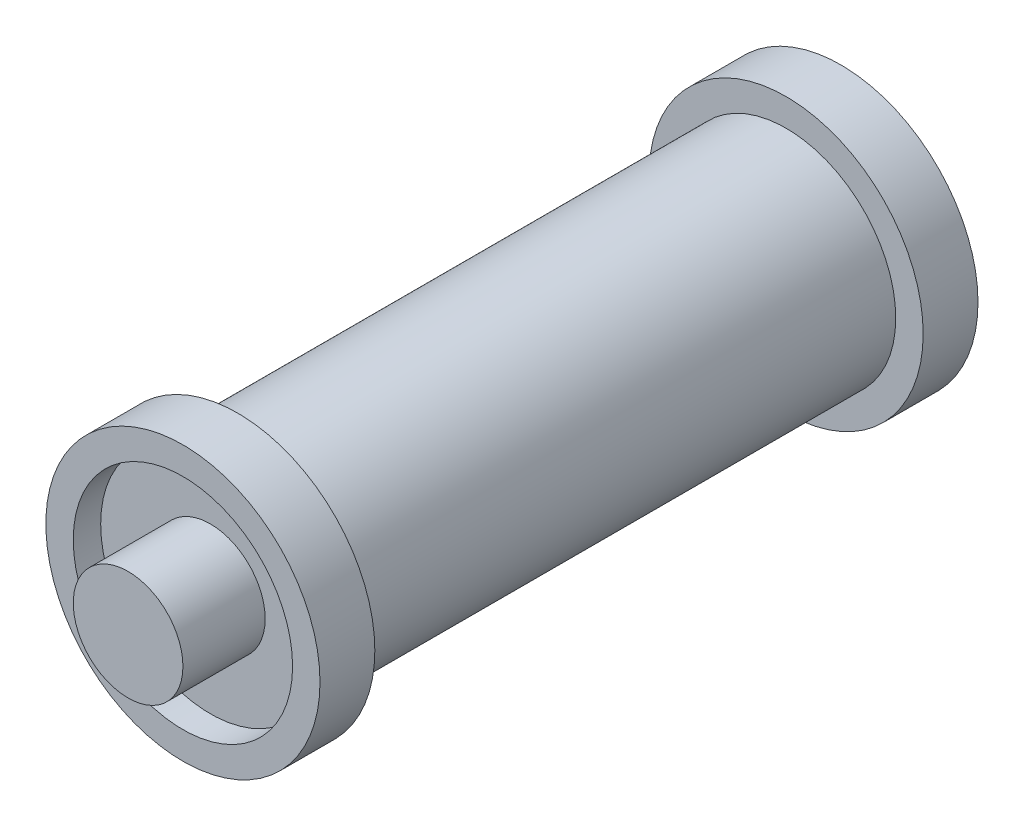
from build123d import *

# Parameters (mm, degrees)
CROQUIS1_R     = 5
EXTRUIR1_DEPTH = 2
VACIADO1_T     = -1
CROQUIS2_R     = 4
EXTRUIR2_DEPTH = 10
CROQUIS4_R     = 2
EXTRUIR4_DEPTH = 3


with BuildPart() as part:
    # Croquis1 → Extruir1 (new body)
    with BuildSketch(Plane.XY):
        Circle(CROQUIS1_R)
    extrude(amount=EXTRUIR1_DEPTH)

    # Vaciado1
    vaciado1_openings = [part.faces().sort_by_distance(p)[0] for p in [
        (0, 0, 2),
    ]]
    offset(amount=VACIADO1_T, openings=vaciado1_openings, kind=Kind.INTERSECTION)

    # Croquis2 → Extruir2 (add)
    with BuildSketch(Plane(origin=(0, 0, 0), x_dir=(-1, 0, 0), z_dir=(0, 0, -1))):
        with Locations(Location((0, 0, 0), (0, 0, 180))):  # turned: the seam where the file's is
            Circle(CROQUIS2_R)
    extrude(amount=EXTRUIR2_DEPTH)

    # Simetría3: part across plane


with BuildPart() as part_1:
    add(part.part)
    add(part.part.mirror(Plane(origin=(0, 0, -10), x_dir=(1, 0, 0), z_dir=(0, 0, -1))))

    # Croquis4 → Extruir4 (add)
    with BuildSketch(Plane.XY.offset(1)):
        Circle(CROQUIS4_R)
    extrude(amount=EXTRUIR4_DEPTH)


solid = part_1.part
